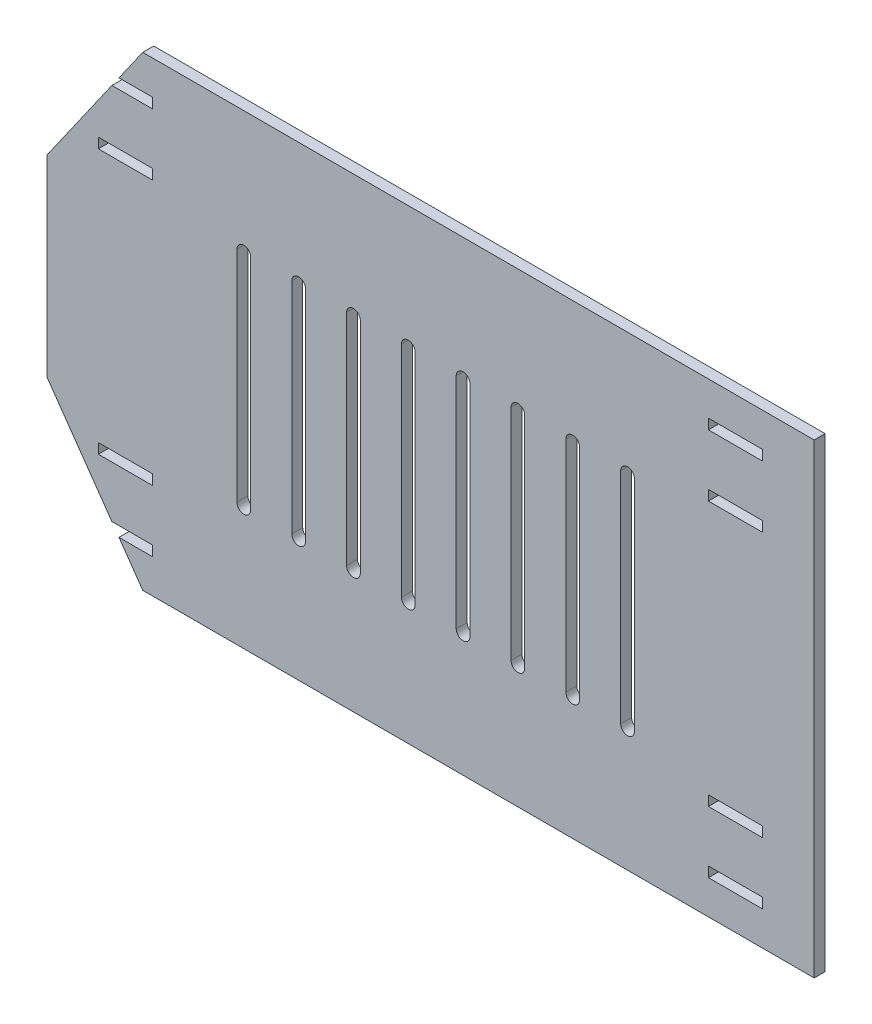
from build123d import *

# Parameters (mm, degrees)
AUFSATZ_LINEAR_AUSTRAGEN1_DEPTH = 4
SKIZZE2_W                       = 19.8
SKIZZE2_H                       = 3.7
SCHNITT_LINEAR_AUSTRAGEN1_DEPTH = 4
SPIEGELN2_COPY_1_SKETCH_W       = 19.8
SPIEGELN2_COPY_1_SKETCH_H       = 3.7
SPIEGELN2_COPY_1_DEPTH          = 4
SCHNITT_LINEAR_AUSTRAGEN2_DEPTH = 4
LINEARES_MUSTER1_COUNT          = 8
LINEARES_MUSTER1_PITCH          = 20
LINEARES_MUSTER1_COPY_1_DEPTH   = 4
LINEARES_MUSTER1_COPY_2_DEPTH   = 4
LINEARES_MUSTER1_COPY_3_DEPTH   = 4
LINEARES_MUSTER1_COPY_4_DEPTH   = 4
LINEARES_MUSTER1_COPY_5_DEPTH   = 4
LINEARES_MUSTER1_COPY_6_DEPTH   = 4
LINEARES_MUSTER1_COPY_7_DEPTH   = 4


with BuildPart() as part:
    # Skizze1 → Aufsatz-Linear austragen1 (new body)
    with BuildSketch(Plane.XY):
        Polygon((35.01037691, 0), (0, 50), (0, 120), (35.01037691, 170), (280, 170), (280, 0), align=None)
    extrude(amount=AUFSATZ_LINEAR_AUSTRAGEN1_DEPTH)

    # Skizze2 → Schnitt-Linear austragen1 (cut)
    with BuildSketch(Plane.XY.offset(4)):
        with Locations((28.7, 155.75)):
            Rectangle(SKIZZE2_W, SKIZZE2_H)
        with Locations((28.7, 133.25)):
            Rectangle(SKIZZE2_W, SKIZZE2_H)
    schnitt_linear_austragen1 = extrude(amount=-SCHNITT_LINEAR_AUSTRAGEN1_DEPTH, mode=Mode.SUBTRACT)

    # Spiegeln1: Schnitt-Linear austragen1 across plane
    add(schnitt_linear_austragen1.mirror(Plane.ZX.offset(85)), mode=Mode.SUBTRACT)

    # Spiegeln2: Schnitt-Linear austragen1 across plane
    add(schnitt_linear_austragen1.mirror(Plane.ZY.offset(-140)), mode=Mode.SUBTRACT)

    # Spiegeln2 copy 1 sketch → Spiegeln2 copy 1 (cut)
    with BuildSketch(Plane(origin=(280, 170, 4), x_dir=(-1, 0, 0), z_dir=(0, 0, 1))):
        with Locations((28.7, 155.75)):
            Rectangle(SPIEGELN2_COPY_1_SKETCH_W, SPIEGELN2_COPY_1_SKETCH_H)
        with Locations((28.7, 133.25)):
            Rectangle(SPIEGELN2_COPY_1_SKETCH_W, SPIEGELN2_COPY_1_SKETCH_H)
    extrude(amount=-SPIEGELN2_COPY_1_DEPTH, mode=Mode.SUBTRACT)

    # Skizze4 → Schnitt-Linear austragen2 (cut)
    with BuildSketch(Plane.XY.offset(4)):
        with BuildLine():
            Line((69.37540934, 85), (74.37540934, 85))
            Line((74.37540934, 85), (74.37540934, 125))
            ThreePointArc((74.37540934, 125), (71.87540934, 127.5), (69.37540934, 125))
            Line((69.37540934, 125), (69.37540934, 85))
        make_face()
    schnitt_linear_austragen2 = extrude(amount=-SCHNITT_LINEAR_AUSTRAGEN2_DEPTH, mode=Mode.SUBTRACT)

    # Spiegeln3: Schnitt-Linear austragen2 across plane
    add(schnitt_linear_austragen2.mirror(Plane.ZX.offset(85)), mode=Mode.SUBTRACT)

    # Lineares Muster1: Schnitt-Linear austragen2 ×8
    with Locations(*[(i * LINEARES_MUSTER1_PITCH, 0, 0) for i in range(1, LINEARES_MUSTER1_COUNT)]):
        add(schnitt_linear_austragen2, mode=Mode.SUBTRACT)

    # Lineares Muster1 copy 1 sketch → Lineares Muster1 copy 1 (cut)
    with BuildSketch(Plane(origin=(20, 170, 4), x_dir=(1, 0, 0), z_dir=(0, 0, 1))):
        with BuildLine():
            Line((69.37540934, -85), (74.37540934, -85))
            Line((74.37540934, -85), (74.37540934, -125))
            ThreePointArc((74.37540934, -125), (71.87540934, -127.5), (69.37540934, -125))
            Line((69.37540934, -125), (69.37540934, -85))
        make_face()
    extrude(amount=-LINEARES_MUSTER1_COPY_1_DEPTH, mode=Mode.SUBTRACT)

    # Lineares Muster1 copy 2 sketch → Lineares Muster1 copy 2 (cut)
    with BuildSketch(Plane(origin=(40, 170, 4), x_dir=(1, 0, 0), z_dir=(0, 0, 1))):
        with BuildLine():
            Line((69.37540934, -85), (74.37540934, -85))
            Line((74.37540934, -85), (74.37540934, -125))
            ThreePointArc((74.37540934, -125), (71.87540934, -127.5), (69.37540934, -125))
            Line((69.37540934, -125), (69.37540934, -85))
        make_face()
    extrude(amount=-LINEARES_MUSTER1_COPY_2_DEPTH, mode=Mode.SUBTRACT)

    # Lineares Muster1 copy 3 sketch → Lineares Muster1 copy 3 (cut)
    with BuildSketch(Plane(origin=(60, 170, 4), x_dir=(1, 0, 0), z_dir=(0, 0, 1))):
        with BuildLine():
            Line((69.37540934, -85), (74.37540934, -85))
            Line((74.37540934, -85), (74.37540934, -125))
            ThreePointArc((74.37540934, -125), (71.87540934, -127.5), (69.37540934, -125))
            Line((69.37540934, -125), (69.37540934, -85))
        make_face()
    extrude(amount=-LINEARES_MUSTER1_COPY_3_DEPTH, mode=Mode.SUBTRACT)

    # Lineares Muster1 copy 4 sketch → Lineares Muster1 copy 4 (cut)
    with BuildSketch(Plane(origin=(80, 170, 4), x_dir=(1, 0, 0), z_dir=(0, 0, 1))):
        with BuildLine():
            Line((69.37540934, -85), (74.37540934, -85))
            Line((74.37540934, -85), (74.37540934, -125))
            ThreePointArc((74.37540934, -125), (71.87540934, -127.5), (69.37540934, -125))
            Line((69.37540934, -125), (69.37540934, -85))
        make_face()
    extrude(amount=-LINEARES_MUSTER1_COPY_4_DEPTH, mode=Mode.SUBTRACT)

    # Lineares Muster1 copy 5 sketch → Lineares Muster1 copy 5 (cut)
    with BuildSketch(Plane(origin=(100, 170, 4), x_dir=(1, 0, 0), z_dir=(0, 0, 1))):
        with BuildLine():
            Line((69.37540934, -85), (74.37540934, -85))
            Line((74.37540934, -85), (74.37540934, -125))
            ThreePointArc((74.37540934, -125), (71.87540934, -127.5), (69.37540934, -125))
            Line((69.37540934, -125), (69.37540934, -85))
        make_face()
    extrude(amount=-LINEARES_MUSTER1_COPY_5_DEPTH, mode=Mode.SUBTRACT)

    # Lineares Muster1 copy 6 sketch → Lineares Muster1 copy 6 (cut)
    with BuildSketch(Plane(origin=(120, 170, 4), x_dir=(1, 0, 0), z_dir=(0, 0, 1))):
        with BuildLine():
            Line((69.37540934, -85), (74.37540934, -85))
            Line((74.37540934, -85), (74.37540934, -125))
            ThreePointArc((74.37540934, -125), (71.87540934, -127.5), (69.37540934, -125))
            Line((69.37540934, -125), (69.37540934, -85))
        make_face()
    extrude(amount=-LINEARES_MUSTER1_COPY_6_DEPTH, mode=Mode.SUBTRACT)

    # Lineares Muster1 copy 7 sketch → Lineares Muster1 copy 7 (cut)
    with BuildSketch(Plane(origin=(140, 170, 4), x_dir=(1, 0, 0), z_dir=(0, 0, 1))):
        with BuildLine():
            Line((69.37540934, -85), (74.37540934, -85))
            Line((74.37540934, -85), (74.37540934, -125))
            ThreePointArc((74.37540934, -125), (71.87540934, -127.5), (69.37540934, -125))
            Line((69.37540934, -125), (69.37540934, -85))
        make_face()
    extrude(amount=-LINEARES_MUSTER1_COPY_7_DEPTH, mode=Mode.SUBTRACT)


solid = part.part
